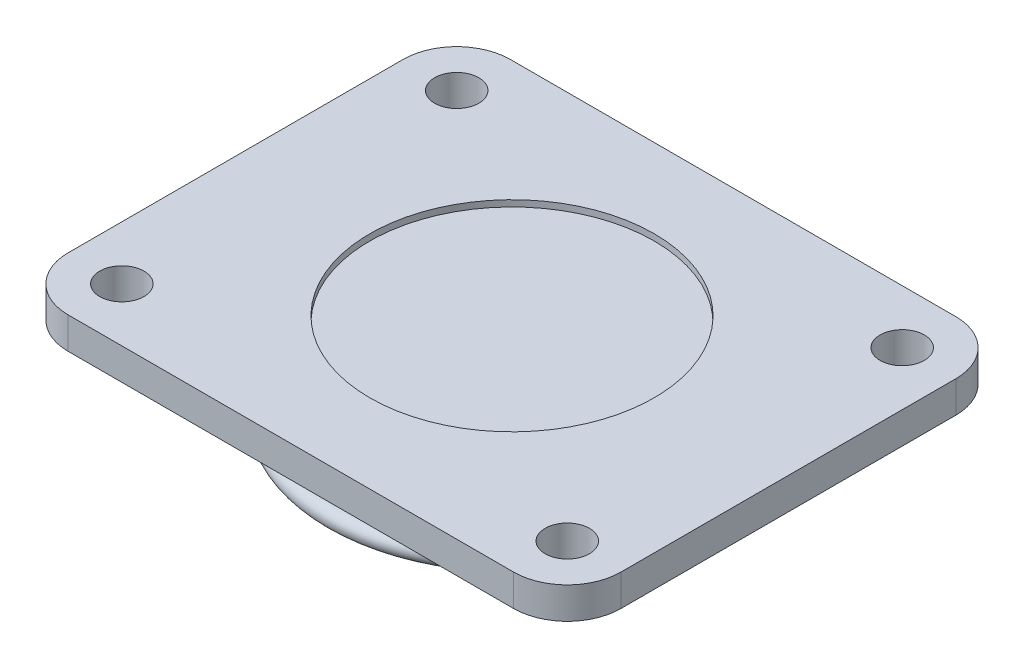
from build123d import *

# Parameters (mm, degrees)
SKETCH1_R           = 7
BOSS_EXTRUDE1_DEPTH = 10
SKETCH2_R           = 56
BOSS_EXTRUDE2_DEPTH = 20
SKETCH3_R           = 3
SKETCH4_R           = 7.5
BOSS_EXTRUDE3_DEPTH = 25
CHAMFER1_SIZE       = 1
SKETCH5_R           = 45
CUT_EXTRUDE1_DEPTH  = 2
SCALE1_SCALE        = 0.18
SCALE2_SCALE        = 1.04


with BuildPart() as part:
    # Sketch1 → Boss-Extrude1 (new body)
    with BuildSketch(Plane(origin=(0, 0, 0), x_dir=(1, 0, 0), z_dir=(0, 1, 0))):
        with BuildLine():
            Line((-70.5, -70), (70.5, -70))
            ThreePointArc((70.5, -70), (82.52081528, -65.02081528), (87.5, -53))
            Line((87.5, -53), (87.5, 53))
            ThreePointArc((87.5, 53), (82.52081528, 65.02081528), (70.5, 70))
            Line((70.5, 70), (-70.5, 70))
            ThreePointArc((-70.5, 70), (-82.52081528, 65.02081528), (-87.5, 53))
            Line((-87.5, 53), (-87.5, -53))
            ThreePointArc((-87.5, -53), (-82.52081528, -65.02081528), (-70.5, -70))
        make_face()
        with Locations((-70.5, 53)):
            Circle(SKETCH1_R, mode=Mode.SUBTRACT)
        with Locations((-70.5, -53)):
            Circle(SKETCH1_R, mode=Mode.SUBTRACT)
        with Locations((70.5, -53)):
            Circle(SKETCH1_R, mode=Mode.SUBTRACT)
        with Locations((70.5, 53)):
            Circle(SKETCH1_R, mode=Mode.SUBTRACT)
    extrude(amount=BOSS_EXTRUDE1_DEPTH)

    # Sketch2 → Boss-Extrude2 (add)
    with BuildSketch(Plane.XZ):
        Circle(SKETCH2_R)
    extrude(amount=BOSS_EXTRUDE2_DEPTH)

    # Sketch3 → Revolve1 (revolve)
    with BuildSketch(Plane(origin=(0, 0, 0), x_dir=(0, 0, -1), z_dir=(1, 0, 0))):
        with Locations((-56, -17)):
            Circle(SKETCH3_R)
    revolve(axis=Axis((0, 0, 0), (0, -1, 0)))

    # Sketch4 → Boss-Extrude3 (add)
    with BuildSketch(Plane.XZ.offset(20)):
        Circle(SKETCH4_R)
    extrude(amount=BOSS_EXTRUDE3_DEPTH)

    # Chamfer1
    chamfer1_edges = [part.edges().sort_by_distance(p)[0] for p in [
        (-7.5, -45, 0),
    ]]
    chamfer(chamfer1_edges, length=CHAMFER1_SIZE)

    # Sketch5 → Cut-Extrude1 (cut)
    with BuildSketch(Plane(origin=(0, 10, 0), x_dir=(1, 0, 0), z_dir=(0, 1, 0))):
        Circle(SKETCH5_R)
    extrude(amount=-CUT_EXTRUDE1_DEPTH, mode=Mode.SUBTRACT)


with BuildPart() as part_1:
    # Scale1: scaled about (0, -2.631964086, 0)
    add(part.part.scale(SCALE1_SCALE).moved(Location((0, -2.158210551, 0))))


with BuildPart() as part_2:
    # Scale2: scaled about (0, -2.631964086, 0)
    add(part_1.part.scale(SCALE2_SCALE).moved(Location((0, 0.105278563, 0))))


solid = part_2.part
